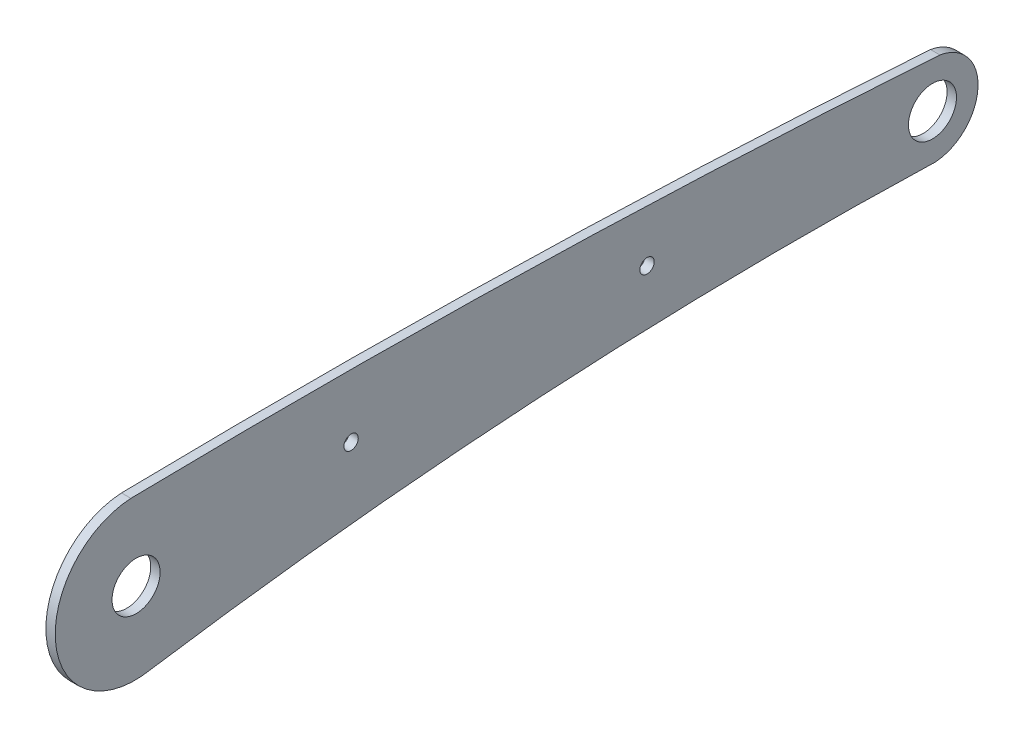
from build123d import *

# Parameters (mm, degrees)
SKETCH_1_R      = 3.85
SKETCH_1_R_2    = 1.149031008
EXTRUDE_1_DEPTH = 1.5


with BuildPart() as part:
    # 草圖1 → 填料-伸長1 (new body)
    with BuildSketch(Plane(origin=(0, 0, 0), x_dir=(0, 0, -1), z_dir=(1, 0, 0))):
        with BuildLine():
            ThreePointArc((66.587683924, -5.116627236), (3.80507147, -6.050846657), (-58.633451622, -12.681082444))
            ThreePointArc((-58.633451622, -12.681082444), (-73.821962275, -1.715080477), (-61.804017134, 12.655481431))
            ThreePointArc((-61.804017134, 12.655481431), (3.033906142, 12.458288366), (67.798504291, 9.369274541))
            ThreePointArc((67.798504291, 9.369274541), (73.912446594, 1.807845069), (67.095645487, -5.12661445))
            ThreePointArc((67.095645487, -5.12661445), (66.8414518, -5.132449469), (66.587683924, -5.116627236))
        make_face()
        with Locations((66.61714054, 2.16157088)):
            Circle(SKETCH_1_R, mode=Mode.SUBTRACT)
        with Locations((-60.969663313, 0.079585479)):
            Circle(SKETCH_1_R, mode=Mode.SUBTRACT)
        with Locations((20.89210292, 3.571177524)):
            Circle(SKETCH_1_R_2, mode=Mode.SUBTRACT)
        with Locations((-26.521912025, 2.797466734)):
            Circle(SKETCH_1_R_2, mode=Mode.SUBTRACT)
    extrude(amount=EXTRUDE_1_DEPTH)


solid = part.part
